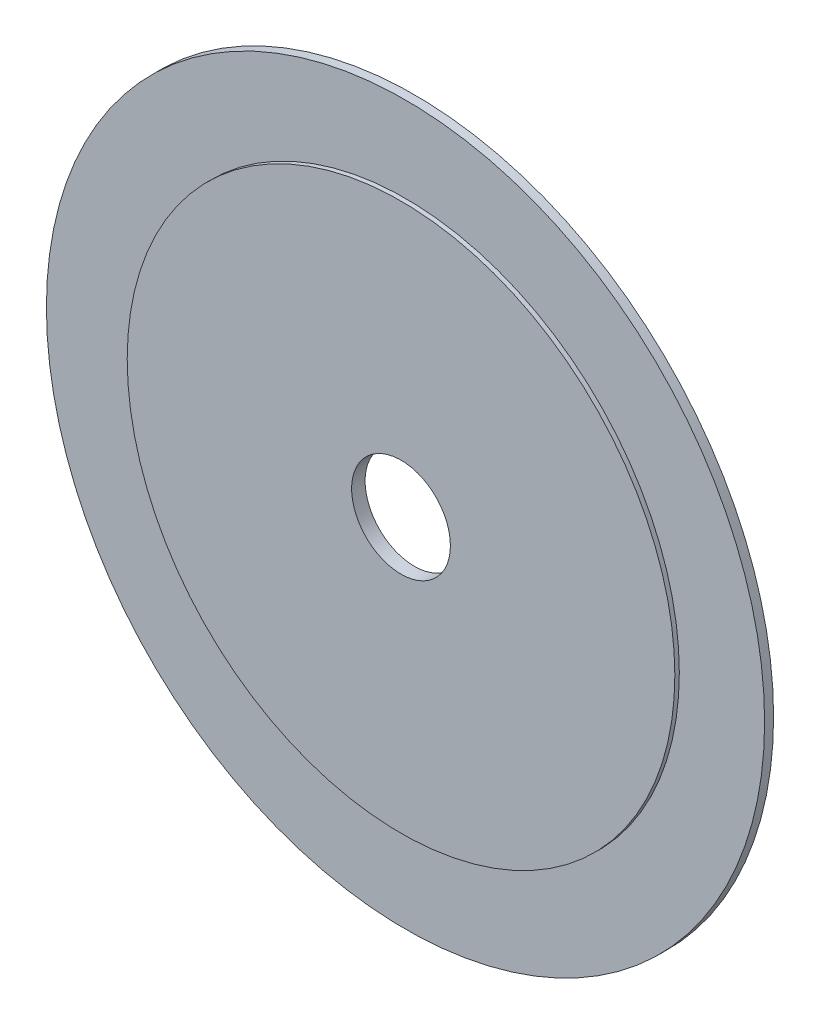
from build123d import *

# Parameters (mm, degrees)
SKETCH1_R           = 80
SKETCH1_R_2         = 11
BOSS_EXTRUDE1_DEPTH = 3
SKETCH2_OUTSIDE_W   = 207.258
SKETCH2_OUTSIDE_H   = 207.258
SKETCH2_OUTSIDE_R   = 61
CUT_EXTRUDE1_DEPTH  = 1


with BuildPart() as part:
    # Sketch1 → Boss-Extrude1 (new body)
    with BuildSketch(Plane.XY):
        Circle(SKETCH1_R)
        Circle(SKETCH1_R_2, mode=Mode.SUBTRACT)
    extrude(amount=BOSS_EXTRUDE1_DEPTH)

    # Sketch2 outside → Cut-Extrude1 (cut)
    with BuildSketch(Plane.XY.offset(3)):
        Rectangle(SKETCH2_OUTSIDE_W, SKETCH2_OUTSIDE_H)
        Circle(SKETCH2_OUTSIDE_R, mode=Mode.SUBTRACT)
    extrude(amount=-CUT_EXTRUDE1_DEPTH, mode=Mode.SUBTRACT)


solid = part.part
